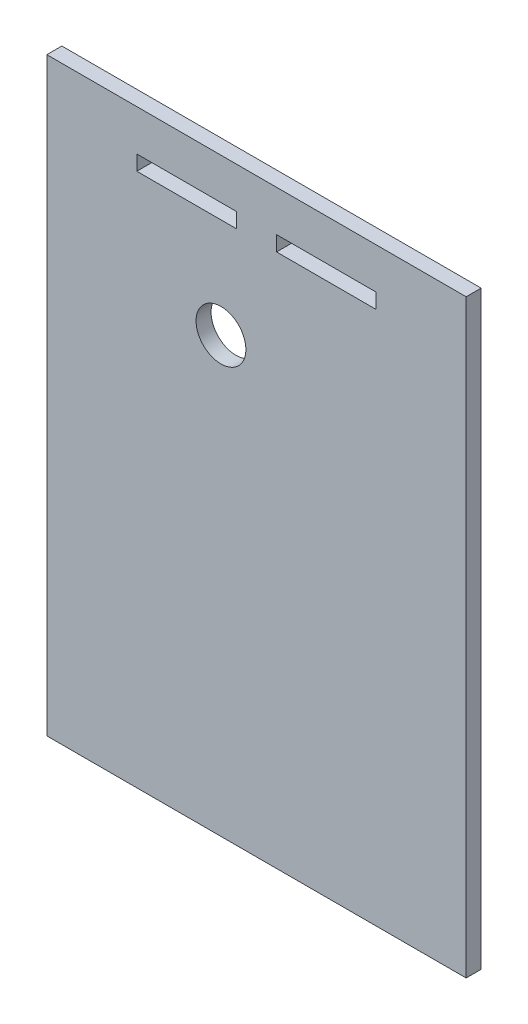
from build123d import *

# Parameters (mm, degrees)
MODEL_R                 = 4.984012051
MODEL_W                 = 19.932346667
MODEL_H                 = 3
SALIENTE_EXTRUIR1_DEPTH = 3


with BuildPart() as part:
    # Model → Saliente-Extruir1 (new body)
    with BuildSketch(Plane.XY):
        Polygon((86.791955129, -43.830425543), (2.925288462, -43.830425543), (2.925288462, 34.469098382), (2.925288462, 74.169574457), (86.791955129, 74.169574457), align=None)
        with Locations((37.750400228, 42.990457696)):
            Circle(MODEL_R, mode=Mode.SUBTRACT)
        with Locations((58.835741796, 64.469574457)):
            Rectangle(MODEL_W, MODEL_H, mode=Mode.SUBTRACT)
        with Locations((30.881501796, 64.469574457)):
            Rectangle(MODEL_W, MODEL_H, mode=Mode.SUBTRACT)
    extrude(amount=SALIENTE_EXTRUIR1_DEPTH)


solid = part.part
